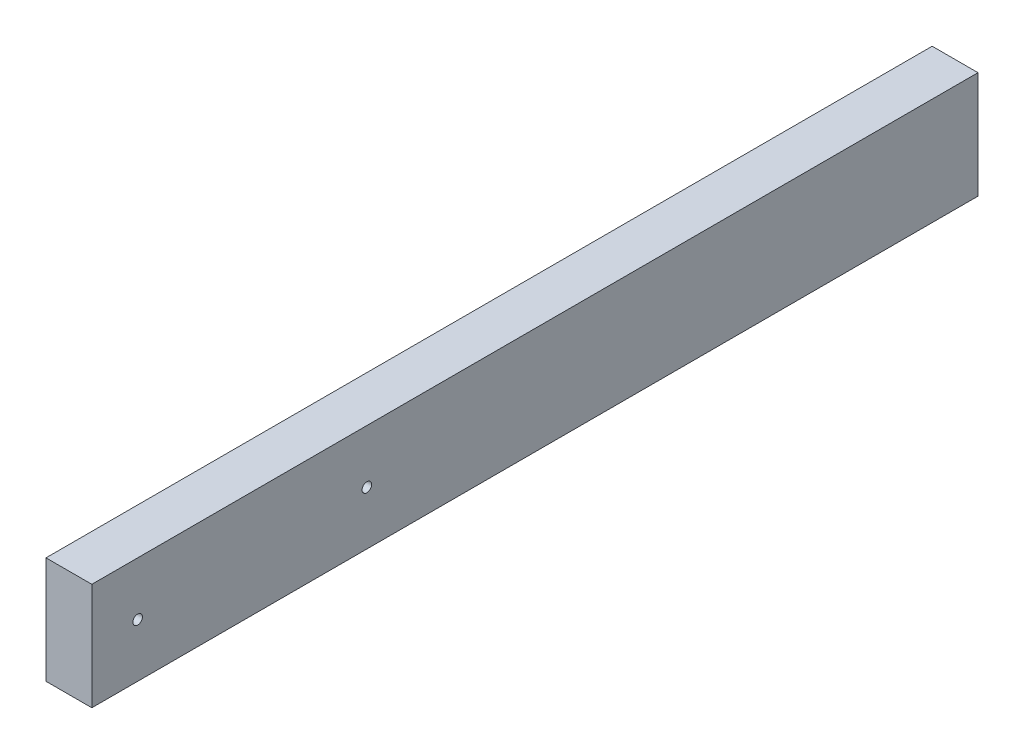
from build123d import *

# Parameters (mm, degrees)
SKETCH1_W                      = 38.1
SKETCH1_H                      = 88.9
BOSS_EXTRUDE1_DEPTH            = 736.6
F_5_16_0_3125_DIAMETER_HOLE1_D = 7.9375


with BuildPart() as part:
    # Sketch1 → Boss-Extrude1 (new body)
    with BuildSketch(Plane.XY):
        Rectangle(SKETCH1_W, SKETCH1_H)
    extrude(amount=BOSS_EXTRUDE1_DEPTH)

    # 5/16 (0.3125) Diameter Hole1 (through all)
    with Locations(Plane(origin=(19.05, 0, 0), x_dir=(0, 0, -1), z_dir=(1, 0, 0))):
        with Locations((-698.5, 0), (-508, 0)):
            Hole(F_5_16_0_3125_DIAMETER_HOLE1_D / 2)


solid = part.part
